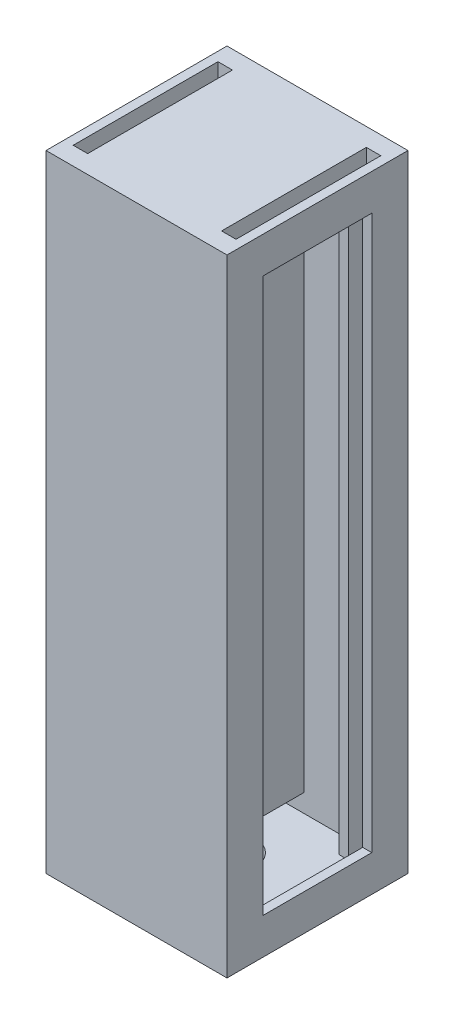
from build123d import *

# Parameters (mm, degrees)
SKETCH1_W           = 31.75
SKETCH1_H           = 31.75
BOSS_EXTRUDE1_DEPTH = 109.855
SHELL1_T            = -3.175
SKETCH2_R           = 4.7625
CUT_EXTRUDE1_DEPTH  = 3.175
SKETCH4_W           = 1.5875
SKETCH4_H           = 3.175
BOSS_EXTRUDE4_DEPTH = 103.505
SKETCH6_W           = 19.05
SKETCH6_H           = 103.505
CUT_EXTRUDE3_DEPTH  = 114.3
SKETCH5_W           = 2.54
SKETCH5_H           = 25.4
CUT_EXTRUDE2_DEPTH  = 106.68
SKETCH8_W           = 19.05
SKETCH8_H           = 3.175
BOSS_EXTRUDE5_DEPTH = 1.5875
SKETCH10_W          = 19.05
SKETCH10_H          = 3.175
BOSS_EXTRUDE7_DEPTH = 1.5875
SKETCH11_W          = 1.5875
SKETCH11_H          = 31.75
BOSS_EXTRUDE8_DEPTH = 103.505
SKETCH13_R          = 6.35
SKETCH13_R_2        = 4.7625
BOSS_EXTRUDE9_DEPTH = 9.525


with BuildPart() as part:
    # Sketch1 → Boss-Extrude1 (new body)
    with BuildSketch(Plane(origin=(0, 0, 0), x_dir=(1, 0, 0), z_dir=(0, 1, 0))):
        Rectangle(SKETCH1_W, SKETCH1_H)
    extrude(amount=BOSS_EXTRUDE1_DEPTH)

    # Shell1
    shell1_openings = [part.faces().sort_by_distance(p)[0] for p in [
        (15.875, 54.9275, 0),
    ]]
    offset(amount=SHELL1_T, openings=shell1_openings, kind=Kind.INTERSECTION)

    # Sketch2 → Cut-Extrude1 (cut)
    with BuildSketch(Plane.XZ):
        Circle(SKETCH2_R)
    extrude(amount=-CUT_EXTRUDE1_DEPTH, mode=Mode.SUBTRACT)

    # Sketch4 → Boss-Extrude4 (add)
    with BuildSketch(Plane(origin=(0, 3.175, 0), x_dir=(1, 0, 0), z_dir=(0, 1, 0))):
        with Locations((15.08125, -11.1125)):
            Rectangle(SKETCH4_W, SKETCH4_H)
        with Locations((15.08125, 11.1125)):
            Rectangle(SKETCH4_W, SKETCH4_H)
        with Locations((10.95375, -11.1125)):
            Rectangle(SKETCH4_W, SKETCH4_H)
        with Locations((10.95375, 11.1125)):
            Rectangle(SKETCH4_W, SKETCH4_H)
        with Locations((-10.95375, 11.1125)):
            Rectangle(SKETCH4_W, SKETCH4_H)
        with Locations((-15.08125, 11.1125)):
            Rectangle(SKETCH4_W, SKETCH4_H)
        with Locations((-15.08125, -11.1125)):
            Rectangle(SKETCH4_W, SKETCH4_H)
        with Locations((-10.95375, -11.1125)):
            Rectangle(SKETCH4_W, SKETCH4_H)
    extrude(amount=BOSS_EXTRUDE4_DEPTH)

    # Sketch6 → Cut-Extrude3 (cut)
    with BuildSketch(Plane(origin=(-12.7, 0, 0), x_dir=(0, 0, -1), z_dir=(1, 0, 0))):
        with Locations((0, 54.9275)):
            Rectangle(SKETCH6_W, SKETCH6_H)
    extrude(amount=-CUT_EXTRUDE3_DEPTH, mode=Mode.SUBTRACT)

    # Sketch5 → Cut-Extrude2 (cut)
    with BuildSketch(Plane(origin=(0, 3.175, 0), x_dir=(1, 0, 0), z_dir=(0, 1, 0))):
        with Locations((13.0175, 0)):
            Rectangle(SKETCH5_W, SKETCH5_H)
        with Locations((-13.0175, 0)):
            Rectangle(SKETCH5_W, SKETCH5_H)
    extrude(amount=CUT_EXTRUDE2_DEPTH, mode=Mode.SUBTRACT)

    # Sketch8 → Boss-Extrude5 (add)
    with BuildSketch(Plane(origin=(15.875, 0, 0), x_dir=(0, 0, -1), z_dir=(1, 0, 0))):
        with Locations((0, 105.0925)):
            Rectangle(SKETCH8_W, SKETCH8_H)
        with Locations((0, 4.7625)):
            Rectangle(SKETCH8_W, SKETCH8_H)
    extrude(amount=-BOSS_EXTRUDE5_DEPTH)

    # Sketch10 → Boss-Extrude7 (add)
    with BuildSketch(Plane.ZY.offset(15.875)):
        with Locations((0, 4.7625)):
            Rectangle(SKETCH10_W, SKETCH10_H)
        with Locations((0, 105.0925)):
            Rectangle(SKETCH10_W, SKETCH10_H)
    extrude(amount=-BOSS_EXTRUDE7_DEPTH)

    # Sketch11 → Boss-Extrude8 (add)
    with BuildSketch(Plane(origin=(0, 109.855, 0), x_dir=(1, 0, 0), z_dir=(0, 1, 0))):
        Rectangle(SKETCH11_W, SKETCH11_H)
    extrude(amount=-BOSS_EXTRUDE8_DEPTH)

    # Sketch13 → Boss-Extrude9 (add)
    with BuildSketch(Plane.XZ):
        Circle(SKETCH13_R)
        Circle(SKETCH13_R_2, mode=Mode.SUBTRACT)
    extrude(amount=BOSS_EXTRUDE9_DEPTH)


solid = part.part
